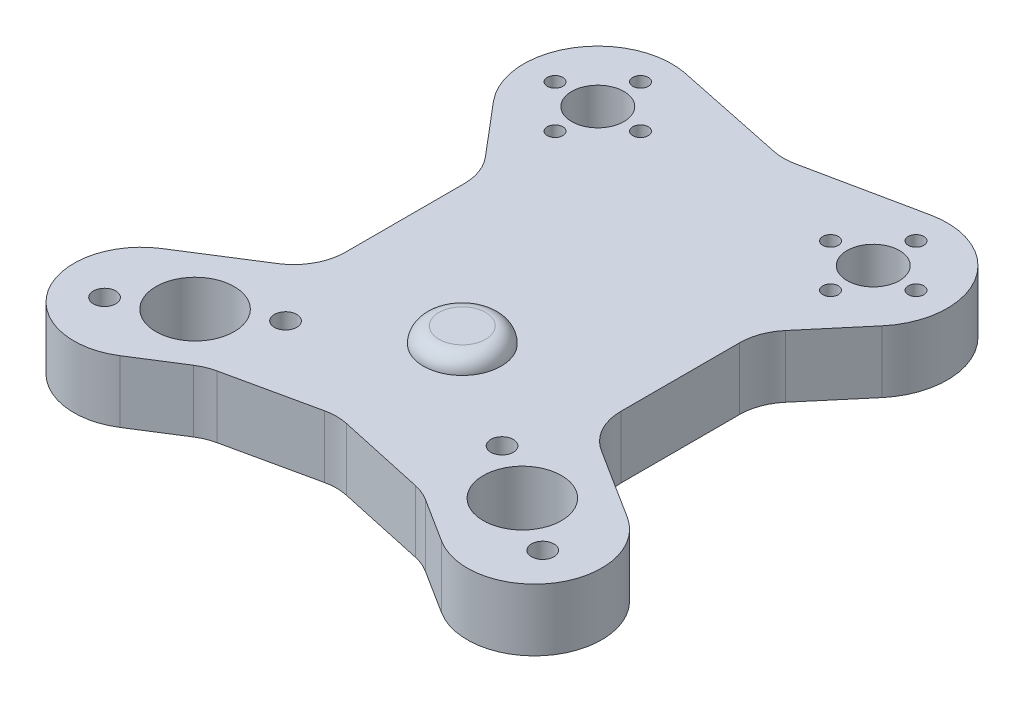
from build123d import *

# Parameters (mm, degrees)
SKETCH1_R           = 5.15
SKETCH1_R_2         = 7.55
SKETCH1_R_3         = 5.05
SKETCH1_R_4         = 1.5
SKETCH1_R_5         = 2.165
BOSS_EXTRUDE1_DEPTH = 12
SKETCH2_ONE_SIDE_W  = 7.5
SKETCH2_ONE_SIDE_H  = 5
FILLET1_R           = 3


with BuildPart() as part:
    # Sketch1 → Boss-Extrude1 (new body)
    with BuildSketch(Plane(origin=(0, 0, 0), x_dir=(1, 0, 0), z_dir=(0, 1, 0))):
        with BuildLine():
            Line((-2.036490016, 62.232628927), (-23.679041405, 66.734453302))
            ThreePointArc((-23.679041405, 66.734453302), (-38.872266056, 60.051931597), (-37.504850395, 43.510458082))
            Line((-37.504850395, 43.510458082), (-28.95403297, 33.398266841))
            ThreePointArc((-28.95403297, 33.398266841), (-27.199588127, 30.379378664), (-26.59, 26.941332001))
            Line((-26.59, 26.941332001), (-26.59, 4.037047599))
            ThreePointArc((-26.59, 4.037047599), (-27.829524982, -0.785200575), (-31.240815491, -4.411989333))
            Line((-31.240815491, -4.411989333), (-44.914180747, -13.06875746))
            ThreePointArc((-44.914180747, -13.06875746), (-48.938899729, -30.983792167), (-31.023865021, -35.008511149))
            Line((-31.023865021, -35.008511149), (-22.386088755, -29.539833551))
            ThreePointArc((-22.386088755, -29.539833551), (-20.83471499, -28.738106539), (-19.167525971, -28.21848405))
            Line((-19.167525971, -28.21848405), (-2.130621725, -24.503257579))
            ThreePointArc((-2.130621725, -24.503257579), (0, -24.273644012), (2.130621725, -24.503257579))
            Line((2.130621725, -24.503257579), (19.167525971, -28.21848405))
            ThreePointArc((19.167525971, -28.21848405), (20.83471499, -28.738106539), (22.386088755, -29.539833551))
            Line((22.386088755, -29.539833551), (31.023865021, -35.008511149))
            ThreePointArc((31.023865021, -35.008511149), (48.938899729, -30.983792167), (44.914180747, -13.06875746))
            Line((44.914180747, -13.06875746), (31.240815491, -4.411989333))
            ThreePointArc((31.240815491, -4.411989333), (27.829524982, -0.785200575), (26.59, 4.037047599))
            Line((26.59, 4.037047599), (26.59, 26.941332001))
            ThreePointArc((26.59, 26.941332001), (27.199588127, 30.379378664), (28.95403297, 33.398266841))
            Line((28.95403297, 33.398266841), (37.504850395, 43.510458082))
            ThreePointArc((37.504850395, 43.510458082), (38.872266056, 60.051931597), (23.679041405, 66.734453302))
            Line((23.679041405, 66.734453302), (2.036490016, 62.232628927))
            ThreePointArc((2.036490016, 62.232628927), (0, 62.023068571), (-2.036490016, 62.232628927))
        make_face()
        Circle(SKETCH1_R, mode=Mode.SUBTRACT)
        with Locations((-31.59, -20)):
            Circle(SKETCH1_R_2, mode=Mode.SUBTRACT)
        with Locations((-26.59, 52.74)):
            Circle(SKETCH1_R_3, mode=Mode.SUBTRACT)
        with Locations((-26.59, 60.99)):
            Circle(SKETCH1_R_4, mode=Mode.SUBTRACT)
        with Locations((-18.34, 52.74)):
            Circle(SKETCH1_R_4, mode=Mode.SUBTRACT)
        with Locations((-26.59, 44.49)):
            Circle(SKETCH1_R_4, mode=Mode.SUBTRACT)
        with Locations((-34.84, 52.74)):
            Circle(SKETCH1_R_4, mode=Mode.SUBTRACT)
        with Locations((-42.286480756, -26.772067589)):
            Circle(SKETCH1_R_5, mode=Mode.SUBTRACT)
        with Locations((-20.893519244, -13.227932411)):
            Circle(SKETCH1_R_5, mode=Mode.SUBTRACT)
        with Locations((20.893519244, -13.227932411)):
            Circle(SKETCH1_R_5, mode=Mode.SUBTRACT)
        with Locations((42.286480756, -26.772067589)):
            Circle(SKETCH1_R_5, mode=Mode.SUBTRACT)
        with Locations((34.84, 52.74)):
            Circle(SKETCH1_R_4, mode=Mode.SUBTRACT)
        with Locations((26.59, 44.49)):
            Circle(SKETCH1_R_4, mode=Mode.SUBTRACT)
        with Locations((18.34, 52.74)):
            Circle(SKETCH1_R_4, mode=Mode.SUBTRACT)
        with Locations((26.59, 60.99)):
            Circle(SKETCH1_R_4, mode=Mode.SUBTRACT)
        with Locations((26.59, 52.74)):
            Circle(SKETCH1_R_3, mode=Mode.SUBTRACT)
        with Locations((31.59, -20)):
            Circle(SKETCH1_R_2, mode=Mode.SUBTRACT)
    extrude(amount=BOSS_EXTRUDE1_DEPTH)


with BuildPart() as body_2:
    # Sketch2 one side → Revolve1 (revolve)
    with BuildSketch(Plane(origin=(0, 0, 0), x_dir=(0, 0, -1), z_dir=(1, 0, 0))):
        with Locations((-3.75, 12.5)):
            Rectangle(SKETCH2_ONE_SIDE_W, SKETCH2_ONE_SIDE_H)
    revolve(axis=Axis((0, 0, 0), (0, 1, 0)))

    # Fillet1
    fillet1_edges = [body_2.edges().sort_by_distance(p)[0] for p in [
        (0, 15, -7.5),
    ]]
    fillet(fillet1_edges, radius=FILLET1_R)


solid = Compound([part.part, body_2.part])
